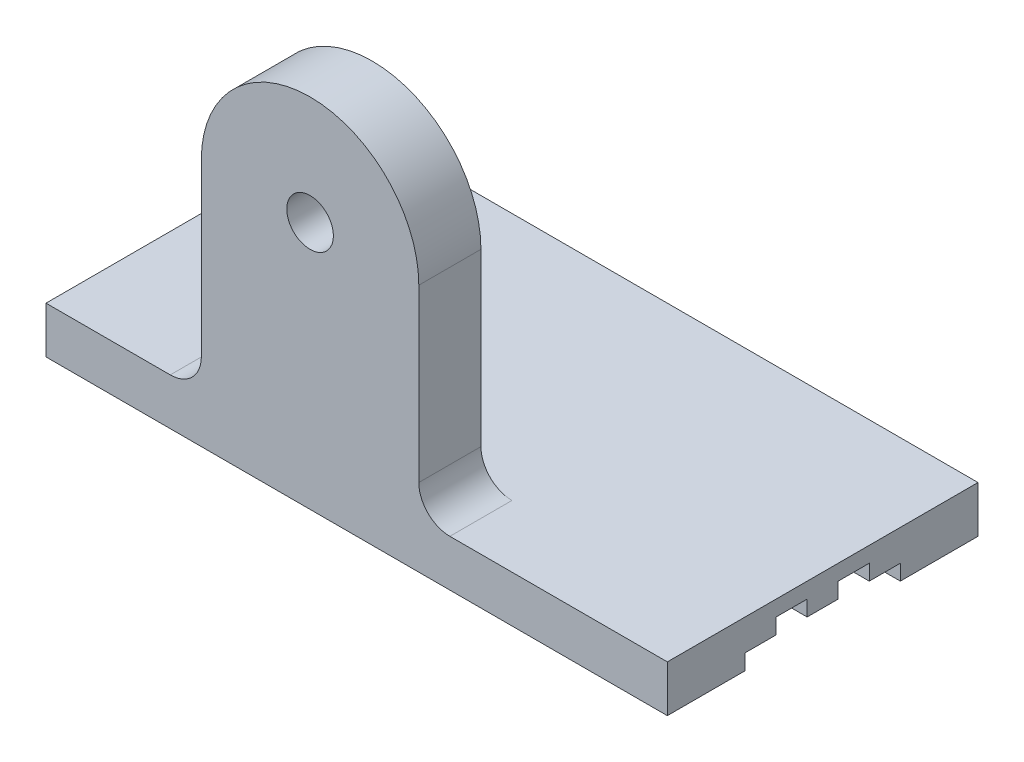
from build123d import *

# Parameters (mm, degrees)
SKETCH_1_W          = 200
SKETCH_1_H          = 100
EXTRUDE_1_DEPTH     = 15
EXTRUDE_2_DEPTH     = 20
CUT_EXTRUDE_2_DEPTH = 201
SKETCH_4_R          = 7.5
CUT_EXTRUDE_3_DEPTH = 101
FILLET_2_R          = 10


with BuildPart() as part:
    # 스케치1 → 보스-돌출1 (new body)
    with BuildSketch(Plane(origin=(0, 0, 0), x_dir=(1, 0, 0), z_dir=(0, 1, 0))):
        with Locations((100, 50)):
            Rectangle(SKETCH_1_W, SKETCH_1_H)
    extrude(amount=EXTRUDE_1_DEPTH)

    # 스케치2 → 보스-돌출2 (add)
    with BuildSketch(Plane.XY):
        with BuildLine():
            Line((50, 0), (120, 0))
            Line((120, 0), (120, 80))
            ThreePointArc((120, 80), (85, 115), (50, 80))
            Line((50, 80), (50, 0))
        make_face()
    extrude(amount=-EXTRUDE_2_DEPTH)

    # 스케치3 → 컷-돌출2 (cut, through all)
    with BuildSketch(Plane(origin=(200, 0, 0), x_dir=(0, 0, -1), z_dir=(1, 0, 0))):
        Polygon((25, 0), (25, 5), (35, 5), (35, 10), (45, 10), (45, 5), (55, 5), (55, 10), (65, 10), (65, 5), (75, 5), (75, 0), align=None)
    extrude(amount=-CUT_EXTRUDE_2_DEPTH, mode=Mode.SUBTRACT)

    # 스케치4 → 컷-돌출3 (cut, through all)
    with BuildSketch(Plane.XY):
        with Locations((85, 80)):
            Circle(SKETCH_4_R)
    extrude(amount=-CUT_EXTRUDE_3_DEPTH, mode=Mode.SUBTRACT)

    # 필렛2
    fillet_2_edges = [part.edges().sort_by_distance(p)[0] for p in [
        (50, 15, -10),
        (120, 15, -10),
    ]]
    fillet(fillet_2_edges, radius=FILLET_2_R)


solid = part.part
